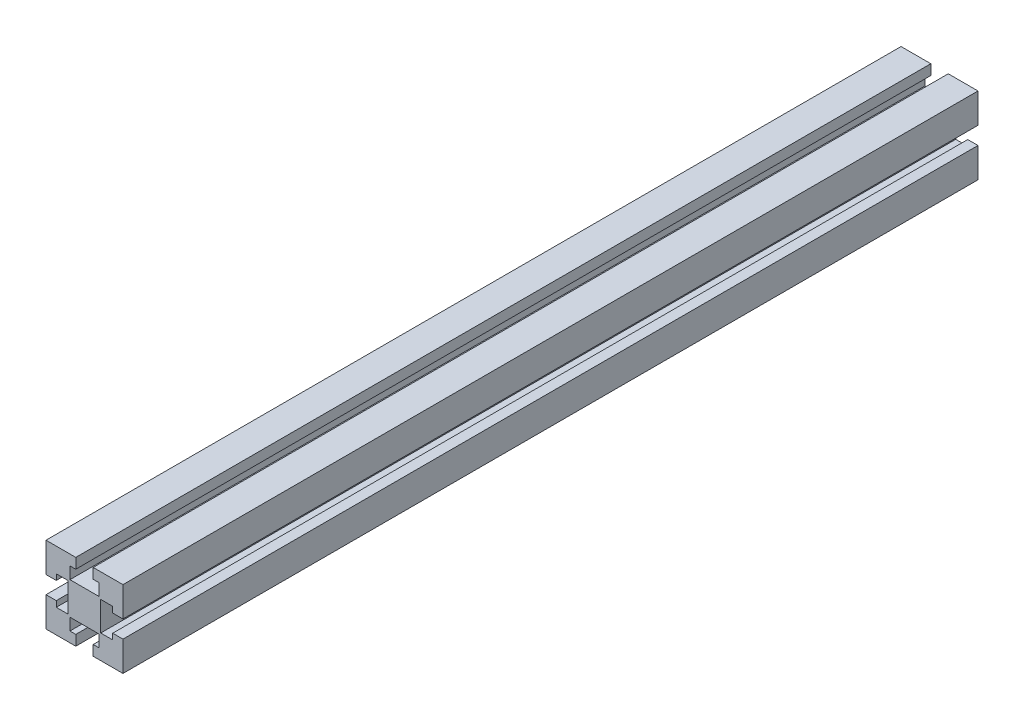
from build123d import *

# Parameters (mm, degrees)
AUFSATZ_LINEAR_AUSTRAGEN1_DEPTH = 500


with BuildPart() as part:
    # Skizze1 → Aufsatz-Linear austragen1 (new body)
    with BuildSketch(Plane.XY):
        Polygon((-18.819236164, 33.776755942), (-1.419236164, 33.776755942), (-1.419236164, 16.376755942), (-7.419236164, 16.376755942), (-7.419236164, 19.781707503), (-14.419236164, 19.781707503), (-14.419236164, 2.77180438), (-7.419236164, 2.77180438), (-7.419236164, 6.176755942), (-1.419236164, 6.176755942), (-1.419236164, -11.223244058), (-18.819236164, -11.223244058), (-18.819236164, -5.223244058), (-15.414284603, -5.223244058), (-15.414284603, 1.776755942), (-32.424187726, 1.776755942), (-32.424187726, -5.223244058), (-29.019236164, -5.223244058), (-29.019236164, -11.223244058), (-46.419236164, -11.223244058), (-46.419236164, 6.176755942), (-40.419236164, 6.176755942), (-40.419236164, 2.77180438), (-33.419236164, 2.77180438), (-33.419236164, 19.781707503), (-40.419236164, 19.781707503), (-40.419236164, 16.376755942), (-46.419236164, 16.376755942), (-46.419236164, 33.776755942), (-29.019236164, 33.776755942), (-29.019236164, 27.776755942), (-32.424187726, 27.776755942), (-32.424187726, 20.776755942), (-15.414284603, 20.776755942), (-15.414284603, 27.776755942), (-18.819236164, 27.776755942), align=None)
    extrude(amount=AUFSATZ_LINEAR_AUSTRAGEN1_DEPTH)


solid = part.part
